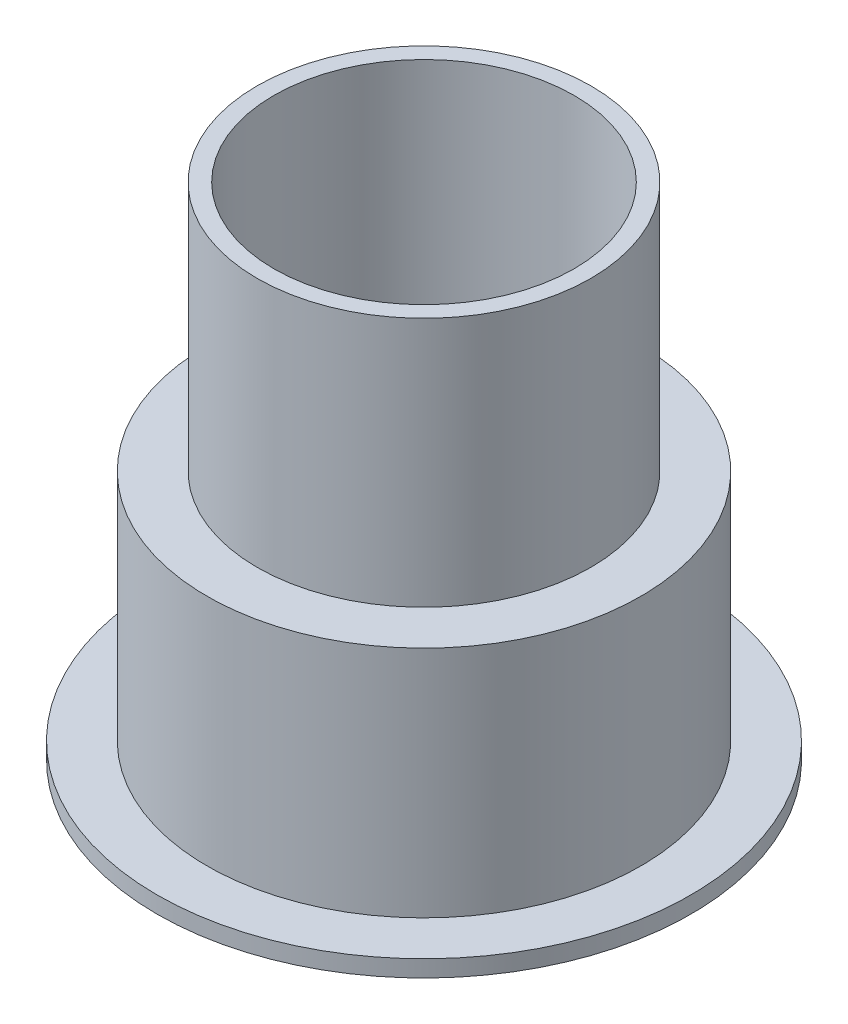
from build123d import *


with BuildPart() as part:
    # Sketch1 → Revolve1 (revolve)
    with BuildSketch(Plane.XY):
        Polygon((6, -0.854835863), (6, 6.145164137), (0, 6.145164137), (0, 6.645164137), (4.5, 6.645164137), (4.5, 14.145164137), (5, 14.145164137), (5, 6.645164137), (6.5, 6.645164137), (6.5, -0.354835863), (8, -0.354835863), (8, -0.854835863), align=None)
    revolve(axis=Axis((0, 0, 0), (0, 1, 0)))


solid = part.part
